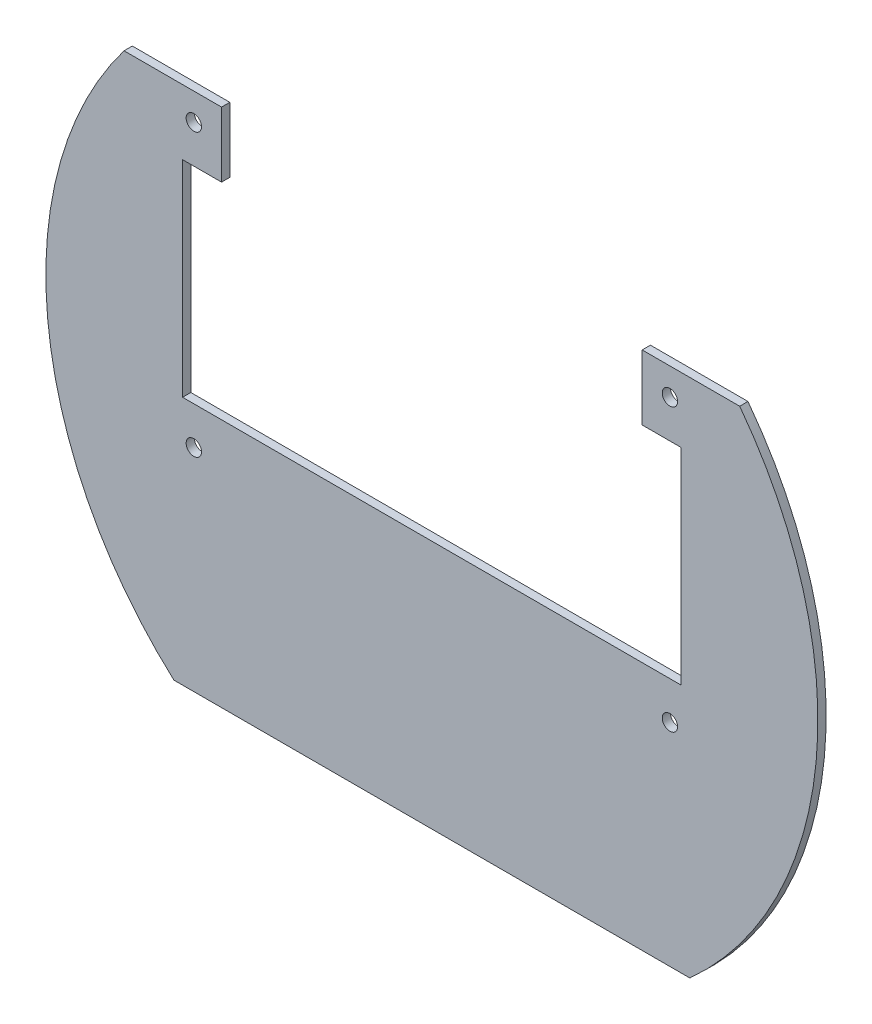
from build123d import *

# Parameters (mm, degrees)
SKETCH1_R           = 1.5
BOSS_EXTRUDE1_DEPTH = 1.6129


with BuildPart() as part:
    # Sketch1 → Boss-Extrude1 (new body)
    with BuildSketch(Plane.XY):
        with BuildLine():
            Line((48.7, 32.8), (41.08, 32.8))
            Line((41.08, 32.8), (41.08, 45.5))
            Line((41.08, 45.5), (60.131959382, 45.5))
            ThreePointArc((60.131959382, 45.5), (75.061798197, -7.199235406), (50.387424414, -56.1))
            Line((50.387424414, -56.1), (-50.387424414, -56.1))
            ThreePointArc((-50.387424414, -56.1), (-75.061798197, -7.199235406), (-60.131959382, 45.5))
            Line((-60.131959382, 45.5), (-41.08, 45.5))
            Line((-41.08, 45.5), (-41.08, 32.8))
            Line((-41.08, 32.8), (-48.7, 32.8))
            Line((-48.7, 32.8), (-48.7, -7.4))
            Line((-48.7, -7.4), (48.7, -7.4))
            Line((48.7, -7.4), (48.7, 32.8))
        make_face()
        with Locations((-46.5, 40.199999991)):
            Circle(SKETCH1_R, mode=Mode.SUBTRACT)
        with Locations((46.5, 40.199999991)):
            Circle(SKETCH1_R, mode=Mode.SUBTRACT)
        with Locations((46.5, -14.799999991)):
            Circle(SKETCH1_R, mode=Mode.SUBTRACT)
        with Locations((-46.5, -14.799999991)):
            Circle(SKETCH1_R, mode=Mode.SUBTRACT)
    extrude(amount=BOSS_EXTRUDE1_DEPTH)


solid = part.part
